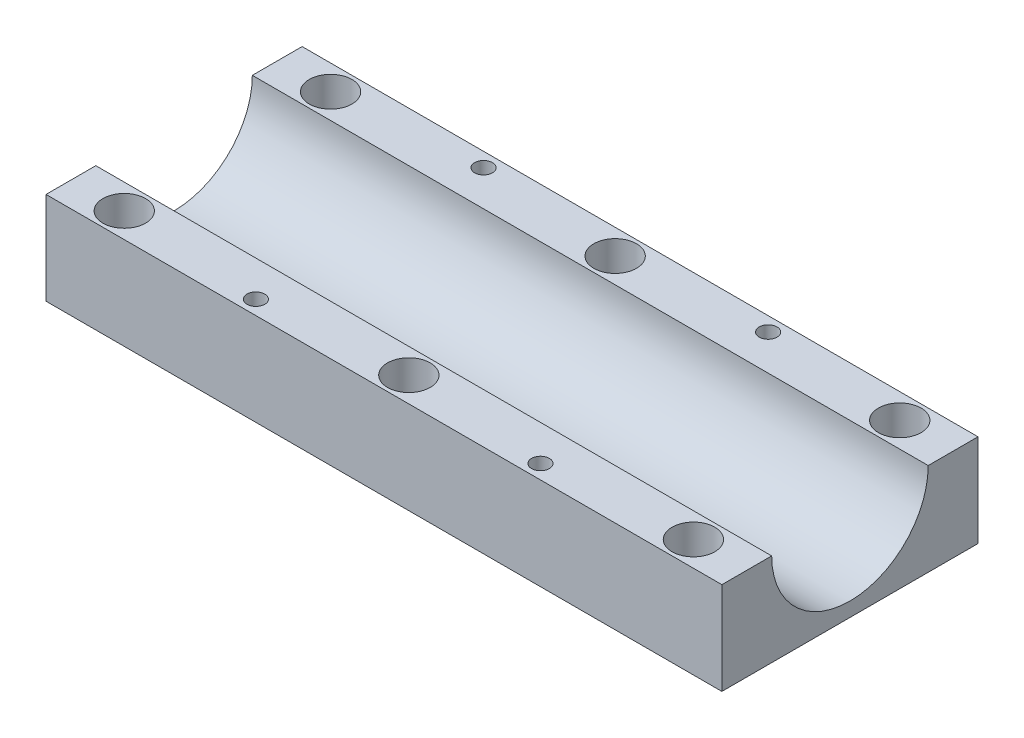
from build123d import *

# Parameters (mm, degrees)
SKETCH_1_W          = 95
SKETCH_1_H          = 36
SKETCH_1_R          = 1.75
EXTRUDE_1_DEPTH     = 13
SKETCH_2_R          = 11
CUT_EXTRUDE_1_DEPTH = 96
SKETCH_4_R          = 3
SKETCH_4_R_2        = 1.25
CUT_EXTRUDE_2_DEPTH = 5


with BuildPart() as part:
    # Эскиз1 → Бобышка-Вытянуть1 (new body)
    with BuildSketch(Plane(origin=(0, 0, 0), x_dir=(1, 0, 0), z_dir=(0, 1, 0))):
        with Locations((47.5, 18)):
            Rectangle(SKETCH_1_W, SKETCH_1_H)
        with Locations((7.5, 32.5)):
            Circle(SKETCH_1_R, mode=Mode.SUBTRACT)
        with Locations((47.5, 32.5)):
            Circle(SKETCH_1_R, mode=Mode.SUBTRACT)
        with Locations((87.5, 32.5)):
            Circle(SKETCH_1_R, mode=Mode.SUBTRACT)
        with Locations((87.5, 3.5)):
            Circle(SKETCH_1_R, mode=Mode.SUBTRACT)
        with Locations((47.5, 3.5)):
            Circle(SKETCH_1_R, mode=Mode.SUBTRACT)
        with Locations((7.5, 3.5)):
            Circle(SKETCH_1_R, mode=Mode.SUBTRACT)
    extrude(amount=EXTRUDE_1_DEPTH)

    # Эскиз2 → Вырез-Вытянуть1 (cut, through all)
    with BuildSketch(Plane(origin=(95, 0, 0), x_dir=(0, 0, -1), z_dir=(1, 0, 0))):
        with Locations((18, 13)):
            Circle(SKETCH_2_R)
    extrude(amount=-CUT_EXTRUDE_1_DEPTH, mode=Mode.SUBTRACT)

    # Эскиз4 → Вырез-Вытянуть2 (cut)
    with BuildSketch(Plane(origin=(0, 13, 0), x_dir=(1, 0, 0), z_dir=(0, 1, 0))):
        with Locations((7.5, 32.5)):
            Circle(SKETCH_4_R)
        with Locations((47.5, 32.5)):
            Circle(SKETCH_4_R)
        with Locations((87.5, 32.5)):
            Circle(SKETCH_4_R)
        with Locations((87.5, 3.5)):
            Circle(SKETCH_4_R)
        with Locations((47.5, 3.5)):
            Circle(SKETCH_4_R)
        with Locations((7.5, 3.5)):
            Circle(SKETCH_4_R)
        with Locations((27.5, 34)):
            Circle(SKETCH_4_R_2)
        with Locations((67.5, 34)):
            Circle(SKETCH_4_R_2)
        with Locations((67.5, 2)):
            Circle(SKETCH_4_R_2)
        with Locations((27.5, 2)):
            Circle(SKETCH_4_R_2)
    extrude(amount=-CUT_EXTRUDE_2_DEPTH, mode=Mode.SUBTRACT)


solid = part.part
